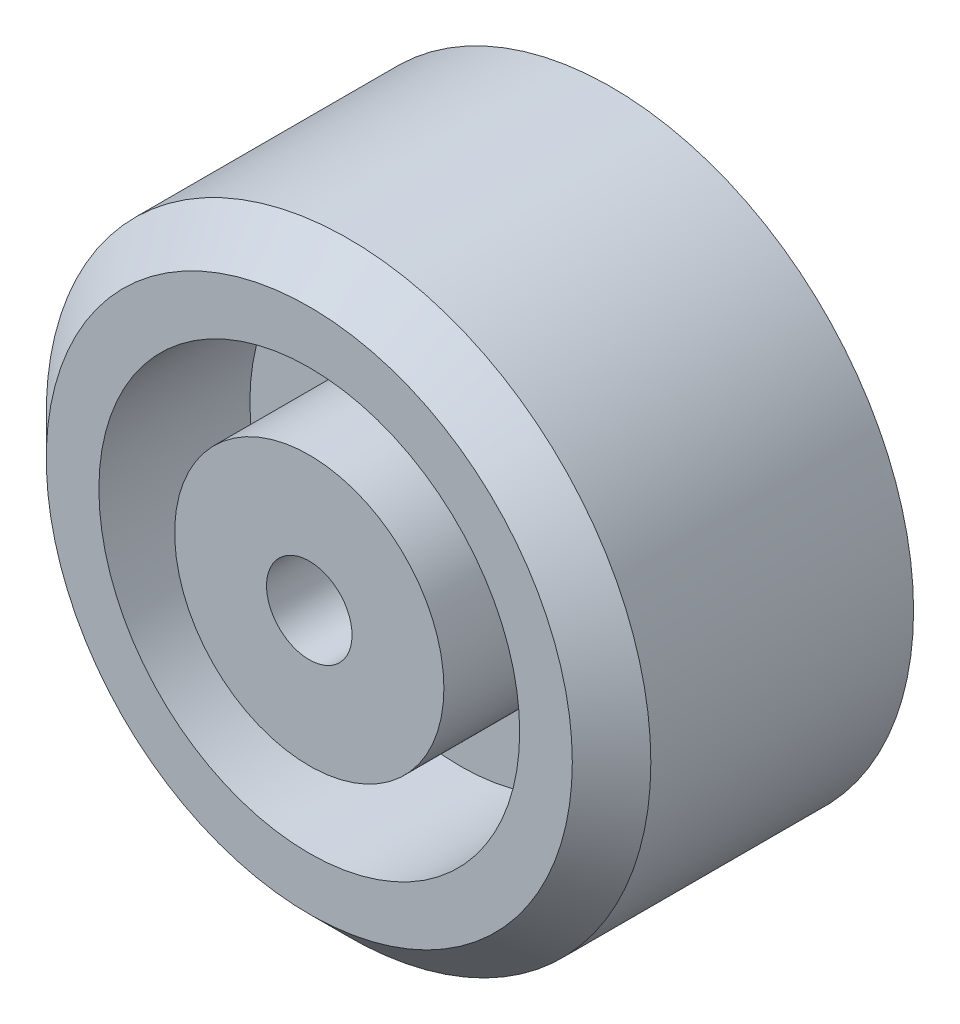
from build123d import *

# Parameters (mm, degrees)
CROQUIS1_R              = 10.009803845
CROQUIS1_R_2            = 1.415393145
SALIENTE_EXTRUIR1_DEPTH = 10
CROQUIS4_R              = 6.966994528
CROQUIS4_R_2            = 4.457512142
CORTAR_EXTRUIR2_DEPTH   = 5
CHAFL_N5_SIZE           = 1.3


with BuildPart() as part:
    # Croquis1 → Saliente-Extruir1 (new body)
    with BuildSketch(Plane.XY):
        with Locations((-9.100662759, 10.663207547)):
            Circle(CROQUIS1_R)
        with Locations((-9.100662759, 10.663207547)):
            Circle(CROQUIS1_R_2, mode=Mode.SUBTRACT)
    extrude(amount=SALIENTE_EXTRUIR1_DEPTH)

    # Croquis4 → Cortar-Extruir2 (cut)
    with BuildSketch(Plane.XY.offset(10)):
        with Locations((-9.100662759, 10.663207547)):
            Circle(CROQUIS4_R)
        with Locations((-9.100662759, 10.663207547)):
            Circle(CROQUIS4_R_2, mode=Mode.SUBTRACT)
    extrude(amount=-CORTAR_EXTRUIR2_DEPTH, mode=Mode.SUBTRACT)

    # Chaflán5
    chafl_n5_edges = [part.edges().sort_by_distance(p)[0] for p in [
        (-19.110466604, 10.663207547, 10),
    ]]
    chamfer(chafl_n5_edges, length=CHAFL_N5_SIZE)


solid = part.part
